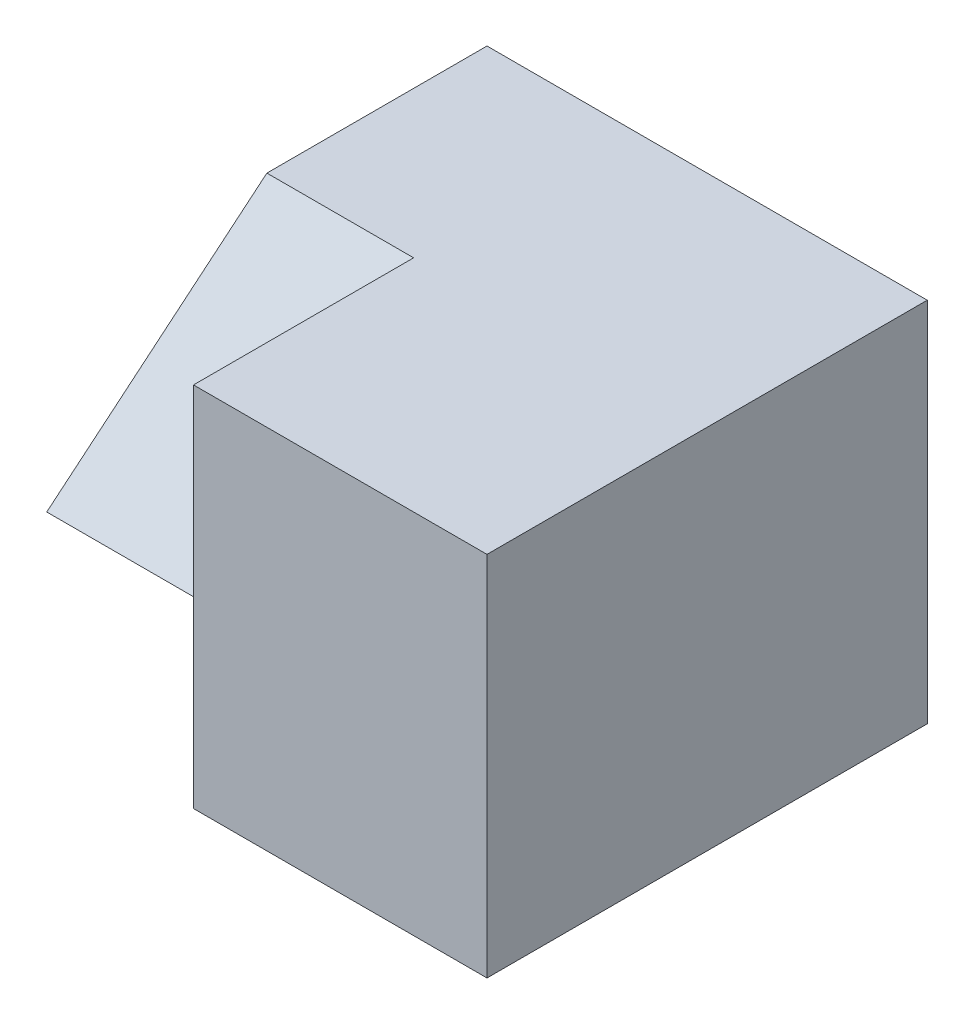
from build123d import *

# Parameters (mm, degrees)
SKETCH1_W           = 6
SKETCH1_H           = 6
BOSS_EXTRUDE1_DEPTH = 5
CUT_EXTRUDE1_DEPTH  = 2


with BuildPart() as part:
    # Sketch1 → Boss-Extrude1 (new body)
    with BuildSketch(Plane(origin=(0, 0, 0), x_dir=(1, 0, 0), z_dir=(0, 1, 0))):
        Rectangle(SKETCH1_W, SKETCH1_H)
    extrude(amount=BOSS_EXTRUDE1_DEPTH)

    # Sketch2 → Cut-Extrude1 (cut)
    with BuildSketch(Plane.ZY.offset(3)):
        Polygon((3, 5), (0, 5), (3, 2.5), align=None)
        Polygon((3, 0), (3, 2.5), (0, 0), align=None)
    extrude(amount=-CUT_EXTRUDE1_DEPTH, mode=Mode.SUBTRACT)


solid = part.part
